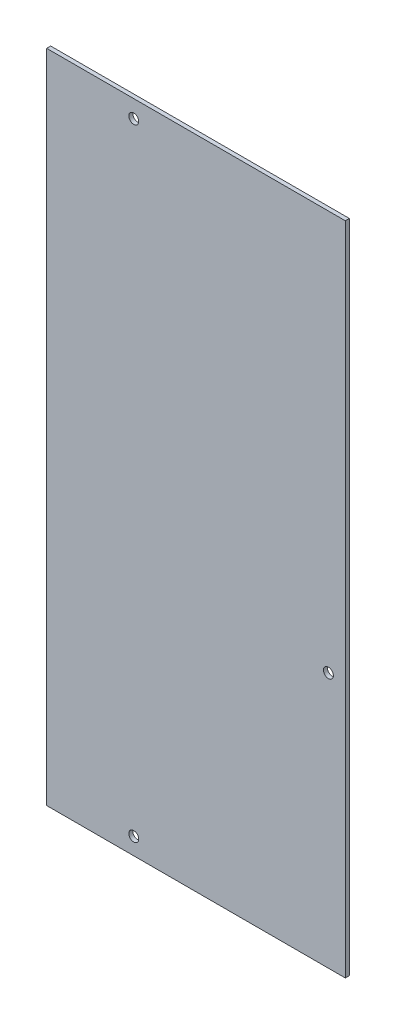
from build123d import *

# Parameters (mm, degrees)
SKETCH1_W           = 228.981
SKETCH1_H           = 502.7676
BOSS_EXTRUDE1_DEPTH = 3.0734
SKETCH2_R           = 3.81
CUT_EXTRUDE1_DEPTH  = 4.0734


with BuildPart() as part:
    # Sketch1 → Boss-Extrude1 (new body)
    with BuildSketch(Plane.XY):
        Rectangle(SKETCH1_W, SKETCH1_H)
    extrude(amount=BOSS_EXTRUDE1_DEPTH)

    # Sketch2 → Cut-Extrude1 (cut, through all)
    with BuildSketch(Plane.XY.offset(3.0734)):
        with Locations((-47.7139, 238.0488)):
            Circle(SKETCH2_R)
        with Locations((-47.7139, -238.4044)):
            Circle(SKETCH2_R)
        with Locations((101.5111, -55.278866667)):
            Circle(SKETCH2_R)
    extrude(amount=-CUT_EXTRUDE1_DEPTH, mode=Mode.SUBTRACT)


solid = part.part
